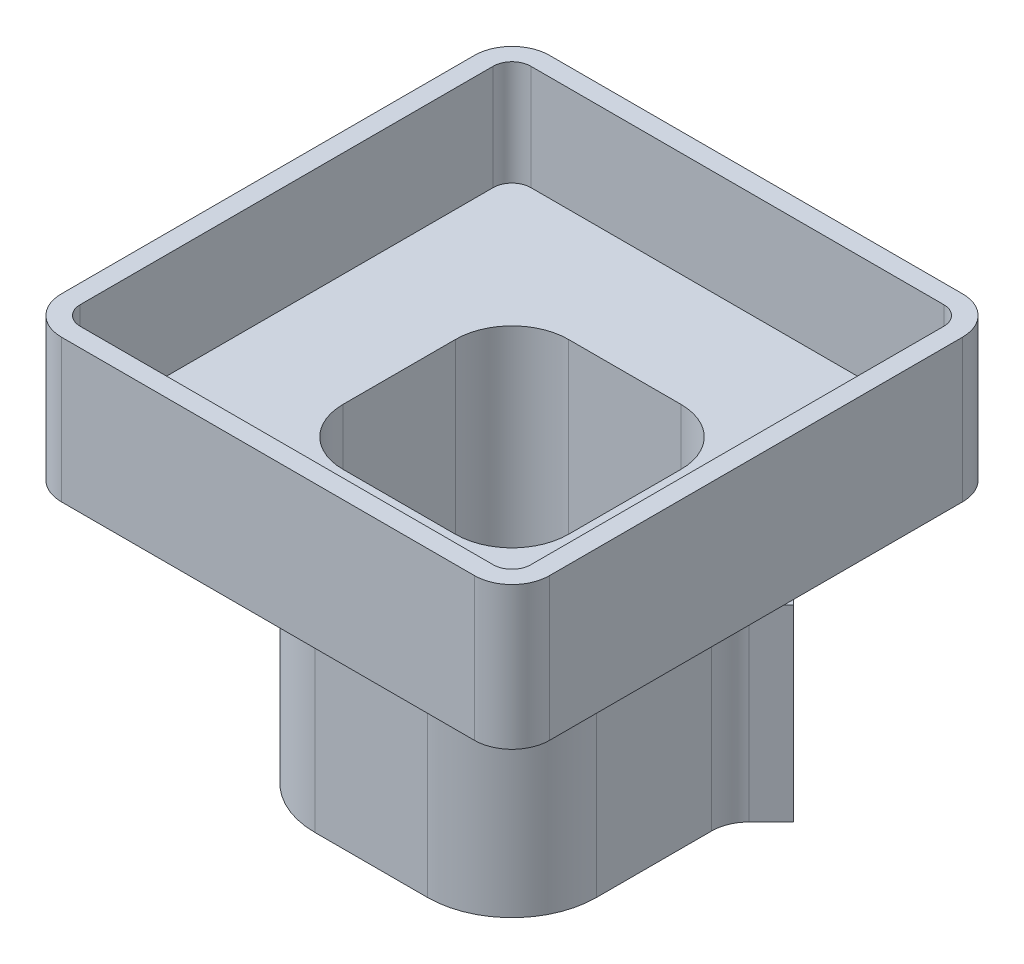
from build123d import *

# Parameters (mm, degrees)
SKETCH1_W                     = 7.5
SKETCH1_H                     = 7.5
BOSS_EXTRUDE1_DEPTH           = 7
SKETCH2_W                     = 13
SKETCH2_H                     = 13
BOSS_EXTRUDE2_DEPTH           = 3.8
SKETCH3_W                     = 6
SKETCH3_H                     = 6
CUT_EXTRUDE1_DEPTH            = 11.8
SKETCH6_W                     = 12
SKETCH6_H                     = 12
CUT_EXTRUDE3_DEPTH            = 2.8
FILLET1_R                     = 0.5
BOSS_EXTRUDE3_REACH           = 12.8
FILLET4_R                     = 1.5
FILLET2_R                     = 1
TAP_DRILL_FOR_0_80_TAP1_D     = 1.19126
TAP_DRILL_FOR_0_80_TAP1_DEPTH = 7.11
TAP_DRILL_FOR_0_80_TAP1_TIP   = 0.357890611
FILLET5_R                     = 2.25
SKETCH16_W                    = 2.5
SKETCH16_H                    = 2
CUT_EXTRUDE4_DEPTH            = 0.835786
FILLET6_R                     = 1


with BuildPart() as part:
    # Sketch1 → Boss-Extrude1 (new body)
    with BuildSketch(Plane(origin=(0, 0, 0), x_dir=(1, 0, 0), z_dir=(0, 1, 0))):
        Rectangle(SKETCH1_W, SKETCH1_H)
    extrude(amount=BOSS_EXTRUDE1_DEPTH)

    # Sketch2 → Boss-Extrude2 (add)
    with BuildSketch(Plane(origin=(0, 7, 0), x_dir=(1, 0, 0), z_dir=(0, 1, 0))):
        Rectangle(SKETCH2_W, SKETCH2_H)
    extrude(amount=BOSS_EXTRUDE2_DEPTH)

    # Sketch3 → Cut-Extrude1 (cut, through all)
    with BuildSketch(Plane.XZ):
        Rectangle(SKETCH3_W, SKETCH3_H)
    extrude(amount=-CUT_EXTRUDE1_DEPTH, mode=Mode.SUBTRACT)

    # Sketch6 → Cut-Extrude3 (cut)
    with BuildSketch(Plane(origin=(0, 10.8, 0), x_dir=(1, 0, 0), z_dir=(0, 1, 0))):
        Rectangle(SKETCH6_W, SKETCH6_H)
    extrude(amount=-CUT_EXTRUDE3_DEPTH, mode=Mode.SUBTRACT)

    # Fillet1
    fillet1_edges = [part.edges().sort_by_distance(p)[0] for p in [
        (6, 9.4, 6),
        (6, 9.4, -6),
        (-6, 9.4, -6),
        (-6, 9.4, 6),
    ]]
    fillet(fillet1_edges, radius=FILLET1_R)

    # Sketch12 → Boss-Extrude3 (add, up to next)
    with BuildSketch(Plane.XZ, mode=Mode.PRIVATE) as boss_extrude3_sk1:
        Polygon((3.75, -3.75), (4.633883476, -2.866116524), (3.75, -1.982233047), align=None)
    boss_extrude3_tool1 = extrude(boss_extrude3_sk1.sketch, amount=-BOSS_EXTRUDE3_REACH, mode=Mode.PRIVATE) - part.part
    add(boss_extrude3_tool1.solids().sort_by_distance((4.044628, 0, -2.866117))[0])
    # Sketch12 → Boss-Extrude3 (add, up to next)
    with BuildSketch(Plane.XZ, mode=Mode.PRIVATE) as boss_extrude3_sk2:
        Polygon((2.866116524, -4.633883476), (3.75, -3.75), (1.982233047, -3.75), align=None)
    boss_extrude3_tool2 = extrude(boss_extrude3_sk2.sketch, amount=-BOSS_EXTRUDE3_REACH, mode=Mode.PRIVATE) - part.part
    add(boss_extrude3_tool2.solids().sort_by_distance((2.866117, 0, -4.044628))[0])

    # Fillet4
    fillet4_edges = [part.edges().sort_by_distance(p)[0] for p in [
        (-3, 4, 3),
        (3, 4, 3),
        (-3, 4, -3),
        (3, 4, -3),
    ]]
    fillet(fillet4_edges, radius=FILLET4_R)

    # Fillet2
    fillet2_edges = [part.edges().sort_by_distance(p)[0] for p in [
        (3.75, 3.5, -1.982233047),
        (1.982233047, 3.5, -3.75),
    ]]
    fillet(fillet2_edges, radius=FILLET2_R)

    # Tap Drill for #0-80 Tap1
    with Locations(Plane(origin=(3.75, 0, -3.75), x_dir=(-0.707106781, 0, -0.707106781), z_dir=(0.707106781, 0, -0.707106781))):
        with Locations((0, 1.25), (0, 3.75)):
            Hole(TAP_DRILL_FOR_0_80_TAP1_D / 2, depth=TAP_DRILL_FOR_0_80_TAP1_DEPTH)
            with Locations((0, 0, -(TAP_DRILL_FOR_0_80_TAP1_DEPTH + TAP_DRILL_FOR_0_80_TAP1_TIP / 2))):  # 118° drill point
                Cone(0, TAP_DRILL_FOR_0_80_TAP1_D / 2, TAP_DRILL_FOR_0_80_TAP1_TIP, mode=Mode.SUBTRACT)

    # Fillet5
    fillet5_edges = [part.edges().sort_by_distance(p)[0] for p in [
        (3.75, 3.5, 3.75),
        (-3.75, 3.5, 3.75),
        (-3.75, 3.5, -3.75),
    ]]
    fillet(fillet5_edges, radius=FILLET5_R)

    # Sketch16 → Cut-Extrude4 (cut)
    with BuildSketch(Plane(origin=(3.75, 0, -3.75), x_dir=(-0.707106781, 0, -0.707106781), z_dir=(0.707106781, 0, -0.707106781))):
        with Locations((0, 6)):
            Rectangle(SKETCH16_W, SKETCH16_H)
    extrude(amount=-CUT_EXTRUDE4_DEPTH, mode=Mode.SUBTRACT)

    # Fillet6
    fillet6_edges = [part.edges().sort_by_distance(p)[0] for p in [
        (-6.5, 8.9, -6.5),
        (-6.5, 8.9, 6.5),
        (6.5, 8.9, 6.5),
        (6.5, 8.9, -6.5),
    ]]
    fillet(fillet6_edges, radius=FILLET6_R)


solid = part.part
